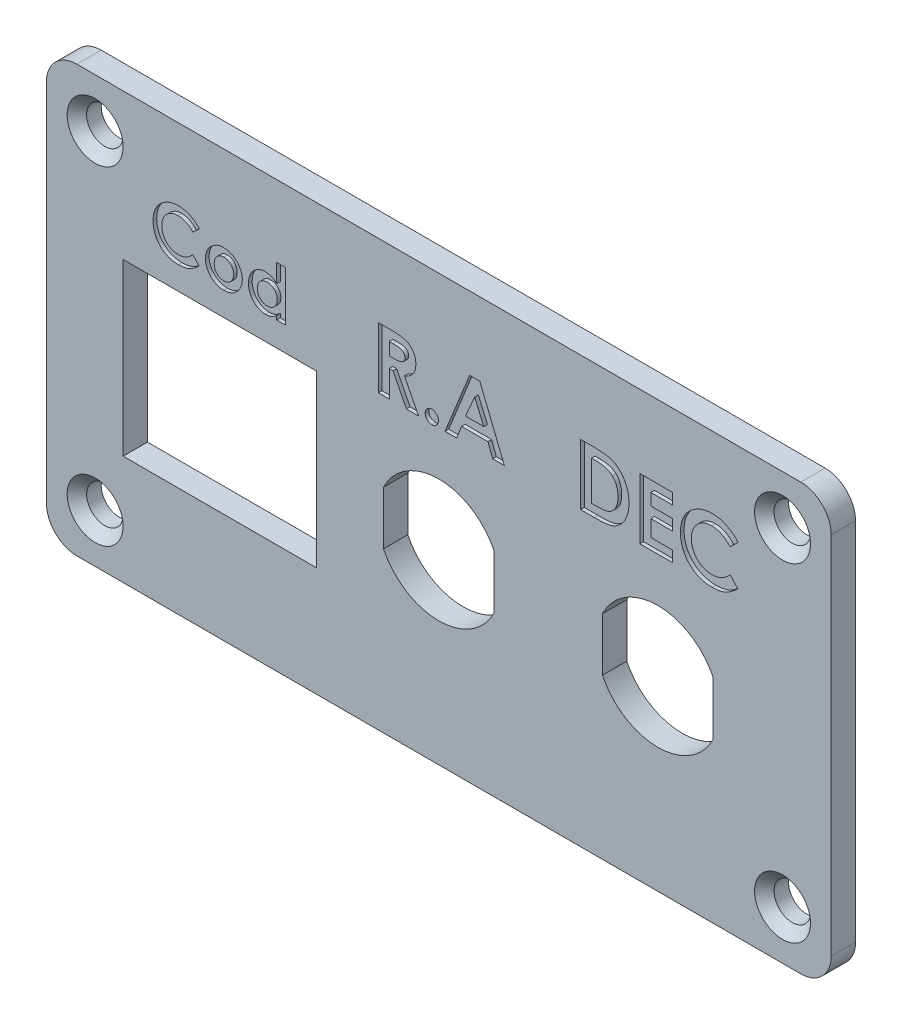
from build123d import *

# Parameters (mm, degrees)
ESQUISSE1_W        = 64.5
ESQUISSE1_H        = 35
ESQUISSE1_R        = 1.5
ESQUISSE1_W_2      = 15.9
ESQUISSE1_H_2      = 14
BOSS_EXTRU_1_DEPTH = 2
CONG_1_R           = 2.5
TEXTE_DEPTH        = 0.3
CHANFREIN1_SIZE    = 0.8


with BuildPart() as part:
    # Esquisse1 → Boss.-Extru.1 (new body)
    with BuildSketch(Plane.XY):
        Rectangle(ESQUISSE1_W, ESQUISSE1_H)
        with Locations((28.25, 13.5)):
            Circle(ESQUISSE1_R, mode=Mode.SUBTRACT)
        with Locations((-28.25, 13.5)):
            Circle(ESQUISSE1_R, mode=Mode.SUBTRACT)
        with Locations((-28.25, -13.5)):
            Circle(ESQUISSE1_R, mode=Mode.SUBTRACT)
        with Locations((28.25, -13.5)):
            Circle(ESQUISSE1_R, mode=Mode.SUBTRACT)
        with BuildLine():
            Line((-4.55, -0.00910977), (-4.55, -4.39089023))
            ThreePointArc((-4.55, -4.39089023), (0, -7.25), (4.55, -4.39089023))
            Line((4.55, -4.39089023), (4.55, -0.00910977))
            ThreePointArc((4.55, -0.00910977), (0, 2.85), (-4.55, -0.00910977))
        make_face(mode=Mode.SUBTRACT)
        with Locations((-18, -1.5)):
            Rectangle(ESQUISSE1_W_2, ESQUISSE1_H_2, mode=Mode.SUBTRACT)
        with BuildLine():
            Line((13.45, -4.39089023), (13.45, -0.00910977))
            ThreePointArc((13.45, -0.00910977), (18, 2.85), (22.55, -0.00910977))
            Line((22.55, -0.00910977), (22.55, -4.39089023))
            ThreePointArc((22.55, -4.39089023), (18, -7.25), (13.45, -4.39089023))
        make_face(mode=Mode.SUBTRACT)
    extrude(amount=BOSS_EXTRU_1_DEPTH)

    # Congé1
    cong_1_edges = [part.edges().sort_by_distance(p)[0] for p in [
        (32.25, -17.5, 1),
        (-32.25, -17.5, 1),
        (-32.25, 17.5, 1),
        (32.25, 17.5, 1),
    ]]
    fillet(cong_1_edges, radius=CONG_1_R)

    # Esquisse2 → Texte (cut)
    with BuildSketch(Plane.XY.offset(2)):
        with BuildLine():
            Line((-4.967948718, 11.5), (-3.922275641, 11.5))
            add(Edge.make_bspline(
                [(-3.922275641, 11.5), (-3.853156969, 11.499754668), (-3.720222293, 11.499282827), (-3.528537751, 11.491838413), (-3.352449138, 11.4814789), (-3.191695739, 11.465670008), (-3.046346327, 11.444709329), (-2.916255229, 11.420000156), (-2.801426245, 11.391838757), (-2.700890954, 11.356747431), (-2.610162824, 11.317164948), (-2.525591594, 11.271683948), (-2.445311496, 11.220810878), (-2.369859116, 11.16320713), (-2.298578754, 11.09990898), (-2.231335937, 11.030852713), (-2.169080867, 10.95545276), (-2.112199031, 10.874185553), (-2.060355816, 10.788694315), (-2.014537288, 10.698861665), (-1.977277584, 10.604625132), (-1.944354642, 10.507346636), (-1.920641313, 10.405635563), (-1.90414904, 10.300482087), (-1.892074042, 10.191516057), (-1.891379788, 10.117489374), (-1.891025641, 10.079727564)],
                knots=[0, 0, 0, 0, 0.000207341, 0.000398776, 0.000575402, 0.000736458, 0.000883205, 0.001015799, 0.001133619, 0.001237515, 0.001334841, 0.001430288, 0.001525314, 0.001619667, 0.00171474, 0.001811071, 0.001908535, 0.00200774, 0.002108399, 0.002208289, 0.002309842, 0.002412147, 0.002516126, 0.002622664, 0.002731397, 0.002844618, 0.002844618, 0.002844618, 0.002844618], degree=3))
            add(Edge.make_bspline(
                [(-1.891025641, 10.079727564), (-1.891945587, 10.040312909), (-1.893749433, 9.963027954), (-1.903465931, 9.849502658), (-1.921224637, 9.740889596), (-1.948122781, 9.637506773), (-1.979038703, 9.53806747), (-2.02014895, 9.444406403), (-2.066545926, 9.355161409), (-2.121650259, 9.271594891), (-2.182124573, 9.19185067), (-2.252454927, 9.118984044), (-2.328084996, 9.049078706), (-2.413266221, 8.98651329), (-2.504243734, 8.92705735), (-2.602825163, 8.873174433), (-2.708367132, 8.823510049), (-2.782568363, 8.795813758), (-2.820512821, 8.781650641)],
                knots=[0, 0, 0, 0, 0.000118257, 0.00023188, 0.000341546, 0.000447947, 0.000552157, 0.000653556, 0.000754365, 0.000853544, 0.000953514, 0.001054124, 0.001156939, 0.001262107, 0.001370733, 0.001482805, 0.001598862, 0.00172032, 0.00172032, 0.00172032, 0.00172032], degree=3))
            Line((-2.820512821, 8.781650641), (-1.666666667, 6.5))
            Line((-1.666666667, 6.5), (-2.664262821, 6.5))
            Line((-2.664262821, 6.5), (-3.766025641, 8.679487179))
            Line((-3.766025641, 8.679487179), (-4.070512821, 8.679487179))
            Line((-4.070512821, 8.679487179), (-4.070512821, 6.5))
            Line((-4.070512821, 6.5), (-4.967948718, 6.5))
            Line((-4.967948718, 6.5), (-4.967948718, 11.5))
        make_face()
        with BuildLine():
            Line((-4.070512821, 9.576923077), (-3.720953526, 9.576923077))
            add(Edge.make_bspline(
                [(-3.720953526, 9.576923077), (-3.678216996, 9.577404404), (-3.596385725, 9.578326043), (-3.478701609, 9.582600986), (-3.371816366, 9.592901485), (-3.275270994, 9.605915781), (-3.188579686, 9.620942666), (-3.112515697, 9.642477103), (-3.045906998, 9.665551798), (-2.989542904, 9.694227658), (-2.941386717, 9.72683833), (-2.899806931, 9.763884865), (-2.865414487, 9.806761511), (-2.837107751, 9.854303067), (-2.815088188, 9.906930027), (-2.799015594, 9.964064664), (-2.790033391, 10.026357817), (-2.788999958, 10.069348574), (-2.788461538, 10.091746795)],
                knots=[0, 0, 0, 0, 0.000128221, 0.000245515, 0.000353154, 0.000450185, 0.000537801, 0.000616775, 0.000687116, 0.000748932, 0.000805883, 0.000861198, 0.000915322, 0.000970118, 0.001026671, 0.001085968, 0.001147728, 0.001214902, 0.001214902, 0.001214902, 0.001214902], degree=3))
            add(Edge.make_bspline(
                [(-2.788461538, 10.091746795), (-2.78947947, 10.118245525), (-2.791479007, 10.17029737), (-2.811320632, 10.245233775), (-2.842904213, 10.314592545), (-2.886196652, 10.3780603), (-2.940717851, 10.433700515), (-3.003285228, 10.482747808), (-3.075249138, 10.521530737), (-3.141882303, 10.547111544), (-3.202502909, 10.562416805), (-3.257211093, 10.57382215), (-3.3205635, 10.581905445), (-3.392607956, 10.590479219), (-3.473160819, 10.596038877), (-3.56266115, 10.600096319), (-3.660851904, 10.601756418), (-3.729300185, 10.602287123), (-3.765024038, 10.602564103)],
                knots=[0, 0, 0, 0, 7.9354e-05, 0.000155877, 0.00023073, 0.000307128, 0.000385047, 0.000463582, 0.000544718, 0.000629358, 0.000676973, 0.000732171, 0.000796904, 0.000868468, 0.00094982, 0.001039053, 0.00113723, 0.001244406, 0.001244406, 0.001244406, 0.001244406], degree=3))
            Line((-3.765024038, 10.602564103), (-4.070512821, 10.602564103))
            Line((-4.070512821, 10.602564103), (-4.070512821, 9.576923077))
        make_face(mode=Mode.SUBTRACT)
        with BuildLine():
            add(Edge.make_bspline(
                [(-0.576923077, 7.525641026), (-0.540694654, 7.523654708), (-0.469367146, 7.519743992), (-0.366308622, 7.490558729), (-0.27329771, 7.438123245), (-0.190133528, 7.369730244), (-0.11981199, 7.287444332), (-0.068985172, 7.19360731), (-0.037334038, 7.090945885), (-0.03383973, 7.019393972), (-0.032051282, 6.982772436)],
                knots=[0, 0, 0, 0, 0.000108636, 0.000213885, 0.000317883, 0.000426763, 0.000535515, 0.000640391, 0.000744962, 0.000854595, 0.000854595, 0.000854595, 0.000854595], degree=3))
            add(Edge.make_bspline(
                [(-0.032051282, 6.982772436), (-0.033828014, 6.946145018), (-0.037299431, 6.874581614), (-0.069204195, 6.771720145), (-0.119736038, 6.677111869), (-0.19013917, 6.59394421), (-0.272953299, 6.524262278), (-0.36652247, 6.472310326), (-0.469170821, 6.441469457), (-0.540660098, 6.437772646), (-0.576923077, 6.435897436)],
                knots=[0, 0, 0, 0, 0.000109633, 0.000214204, 0.000319962, 0.00042948, 0.000538999, 0.000642997, 0.000748527, 0.000857163, 0.000857163, 0.000857163, 0.000857163], degree=3))
            add(Edge.make_bspline(
                [(-0.576923077, 6.435897436), (-0.613194648, 6.437757397), (-0.684700864, 6.441424147), (-0.787508775, 6.472570284), (-0.881768747, 6.523915427), (-0.964603683, 6.594028734), (-1.035321345, 6.676817365), (-1.084416521, 6.772018651), (-1.116618469, 6.874542833), (-1.120042429, 6.946131889), (-1.121794872, 6.982772436)],
                knots=[0, 0, 0, 0, 0.000108636, 0.000214166, 0.000319043, 0.000428562, 0.00053808, 0.000643368, 0.000747938, 0.000857571, 0.000857571, 0.000857571, 0.000857571], degree=3))
            add(Edge.make_bspline(
                [(-1.121794872, 6.982772436), (-1.120030867, 7.019407329), (-1.116584318, 7.09098534), (-1.08463492, 7.193305366), (-1.035242661, 7.287740436), (-0.96460958, 7.369645544), (-0.881422561, 7.438467388), (-0.787723823, 7.490302332), (-0.684504639, 7.519789637), (-0.613160133, 7.523670083), (-0.576923077, 7.525641026)],
                knots=[0, 0, 0, 0, 0.000109633, 0.000214204, 0.000318606, 0.000427357, 0.000536237, 0.000641114, 0.000746364, 0.000854999, 0.000854999, 0.000854999, 0.000854999], degree=3))
        make_face()
        Polygon((2.533052885, 11.5), (3.365384615, 11.5), (5.384615385, 6.5), (4.426081731, 6.5), (4.037459936, 7.525641026), (1.858974359, 7.525641026), (1.470352564, 6.5), (0.512820513, 6.5), align=None)
        Polygon((2.948717949, 10.158854167), (2.199519231, 8.423076923), (3.697916667, 8.423076923), align=None, mode=Mode.SUBTRACT)
        with BuildLine():
            Line((11.653846154, 11.5), (12.784655449, 11.5))
            add(Edge.make_bspline(
                [(12.784655449, 11.5), (12.87281504, 11.499383734), (13.043228526, 11.498192486), (13.290123955, 11.484769979), (13.519705285, 11.464127116), (13.73212051, 11.435729118), (13.926934144, 11.398150789), (14.103894979, 11.351016141), (14.263596938, 11.296607031), (14.40779112, 11.232583672), (14.539426538, 11.157938794), (14.66441857, 11.074790393), (14.782521795, 10.9800925), (14.895393605, 10.875672026), (15.001577366, 10.75961863), (15.102841419, 10.633854577), (15.196706359, 10.496556115), (15.28600952, 10.351015228), (15.366772346, 10.196615127), (15.437216701, 10.034670034), (15.496228364, 9.866222127), (15.544178397, 9.691091883), (15.582400106, 9.509860681), (15.609143066, 9.322162815), (15.625675831, 9.12817206), (15.627352941, 8.996695), (15.628205128, 8.929887821)],
                knots=[0, 0, 0, 0, 0.000264453, 0.000511191, 0.000741521, 0.000955838, 0.001153841, 0.001336301, 0.001504814, 0.001659496, 0.001808829, 0.001958283, 0.002109389, 0.002262474, 0.002419124, 0.002580867, 0.002746456, 0.002917718, 0.003092887, 0.003268727, 0.003447072, 0.00362786, 0.003813103, 0.004002345, 0.004196317, 0.0043967, 0.0043967, 0.0043967, 0.0043967], degree=3))
            add(Edge.make_bspline(
                [(15.628205128, 8.929887821), (15.625973643, 8.835618541), (15.621580833, 8.650043947), (15.584578256, 8.377715368), (15.524732561, 8.116661263), (15.440584078, 7.868923699), (15.336262485, 7.636708815), (15.21163866, 7.424111624), (15.068539879, 7.232273239), (14.908633252, 7.062148859), (14.735493319, 6.915924649), (14.555566015, 6.790694313), (14.36709852, 6.691939744), (14.201032318, 6.629314579), (14.057032202, 6.590367145), (13.930601659, 6.567348836), (13.786989462, 6.546239659), (13.624856552, 6.52992694), (13.444914171, 6.515380005), (13.246445067, 6.507475766), (13.030091826, 6.500908517), (12.879814044, 6.500310774), (12.801682692, 6.5)],
                knots=[0, 0, 0, 0, 0.000282708, 0.000556526, 0.000822811, 0.001085071, 0.001340133, 0.001585264, 0.001822845, 0.002056671, 0.002284055, 0.002501589, 0.002713051, 0.002920663, 0.003032668, 0.003160155, 0.003305912, 0.003468066, 0.003648899, 0.003847421, 0.004063851, 0.004298234, 0.004298234, 0.004298234, 0.004298234], degree=3))
            Line((12.801682692, 6.5), (11.653846154, 6.5))
            Line((11.653846154, 6.5), (11.653846154, 11.5))
        make_face()
        with BuildLine():
            Line((12.551282051, 10.602564103), (12.551282051, 7.397435897))
            Line((12.551282051, 7.397435897), (13.020032051, 7.397435897))
            add(Edge.make_bspline(
                [(13.020032051, 7.397435897), (13.075806102, 7.397538099), (13.18307817, 7.397734665), (13.337954753, 7.407097314), (13.481176323, 7.416494831), (13.612348623, 7.434331632), (13.732426285, 7.454200574), (13.839759756, 7.481850927), (13.936561646, 7.51089528), (14.021649537, 7.547872342), (14.099583113, 7.589492486), (14.171740703, 7.63825531), (14.241392979, 7.692404586), (14.307237737, 7.753532923), (14.369524183, 7.820830867), (14.427883791, 7.894645172), (14.483095507, 7.974750631), (14.533742151, 8.061570781), (14.580023325, 8.15418878), (14.621079913, 8.251707489), (14.655121883, 8.354939029), (14.683415484, 8.462917028), (14.703634471, 8.576581557), (14.720361825, 8.695090719), (14.728985264, 8.818914037), (14.730168777, 8.90316756), (14.730769231, 8.945913462)],
                knots=[0, 0, 0, 0, 0.00016728, 0.000321734, 0.000465387, 0.000597697, 0.000718729, 0.000830231, 0.000930015, 0.001021551, 0.001108043, 0.001194715, 0.001282474, 0.00137249, 0.001463922, 0.001557308, 0.001654546, 0.001755554, 0.001858578, 0.001964979, 0.002072669, 0.002184418, 0.002299537, 0.002418808, 0.002543333, 0.002671573, 0.002671573, 0.002671573, 0.002671573], degree=3))
            add(Edge.make_bspline(
                [(14.730769231, 8.945913462), (14.729573331, 9.011417514), (14.727241419, 9.139145341), (14.704752963, 9.325183709), (14.668146047, 9.500366702), (14.615911504, 9.66404417), (14.550068245, 9.816676131), (14.467650057, 9.95696947), (14.372203902, 10.087280922), (14.296727687, 10.1637258), (14.259014423, 10.201923077)],
                knots=[0, 0, 0, 0, 0.000196439, 0.000383041, 0.000561217, 0.000732585, 0.000897642, 0.001058779, 0.001219838, 0.001380685, 0.001380685, 0.001380685, 0.001380685], degree=3))
            add(Edge.make_bspline(
                [(14.259014423, 10.201923077), (14.221825574, 10.23447232), (14.145871562, 10.300950464), (14.012521275, 10.380608281), (13.865576166, 10.450595482), (13.70167457, 10.506087526), (13.522400524, 10.549973001), (13.326686267, 10.58023974), (13.115579893, 10.599688825), (12.969330316, 10.601585143), (12.893830128, 10.602564103)],
                knots=[0, 0, 0, 0, 0.000147993, 0.00030226, 0.000464002, 0.000635683, 0.000820307, 0.001017083, 0.001229276, 0.001455718, 0.001455718, 0.001455718, 0.001455718], degree=3))
            Line((12.893830128, 10.602564103), (12.551282051, 10.602564103))
        make_face(mode=Mode.SUBTRACT)
        Polygon((16.525641026, 11.5), (19.217948718, 11.5), (19.217948718, 10.602564103), (17.423076923, 10.602564103), (17.423076923, 9.641025641), (19.217948718, 9.641025641), (19.217948718, 8.743589744), (17.423076923, 8.743589744), (17.423076923, 7.397435897), (19.217948718, 7.397435897), (19.217948718, 6.5), (16.525641026, 6.5), align=None)
        with BuildLine():
            Line((24.602564103, 10.632612179), (23.944511218, 10.003605769))
            add(Edge.make_bspline(
                [(23.944511218, 10.003605769), (23.888689811, 10.061325197), (23.779653116, 10.174069323), (23.603953966, 10.32333261), (23.421233247, 10.447723364), (23.235045427, 10.552484465), (23.042041525, 10.631743704), (22.844453193, 10.689501246), (22.641018771, 10.724713837), (22.503342179, 10.72874278), (22.434094551, 10.730769231)],
                knots=[0, 0, 0, 0, 0.000240802, 0.000470361, 0.000690114, 0.000903069, 0.001110094, 0.001314541, 0.001519711, 0.001727335, 0.001727335, 0.001727335, 0.001727335], degree=3))
            add(Edge.make_bspline(
                [(22.434094551, 10.730769231), (22.376264367, 10.729168264), (22.262142869, 10.726008933), (22.094582605, 10.702847918), (21.934302552, 10.663461605), (21.780754048, 10.60917997), (21.634388914, 10.538942415), (21.494900278, 10.452803302), (21.362632044, 10.35154059), (21.239331399, 10.235678217), (21.126540301, 10.109089868), (21.026882185, 9.974020401), (20.943402526, 9.830779254), (20.874892128, 9.680817067), (20.821525177, 9.52343974), (20.783414468, 9.358753228), (20.761372253, 9.1865614), (20.758082305, 9.069506679), (20.756410256, 9.010016026)],
                knots=[0, 0, 0, 0, 0.000173462, 0.000342309, 0.000506284, 0.00066785, 0.000830023, 0.00099236, 0.001158834, 0.001328906, 0.001499173, 0.001666851, 0.001831592, 0.001995638, 0.002160659, 0.002329274, 0.00250196, 0.002680425, 0.002680425, 0.002680425, 0.002680425], degree=3))
            add(Edge.make_bspline(
                [(20.756410256, 9.010016026), (20.756892122, 8.968261323), (20.757841888, 8.885961946), (20.768238761, 8.764218326), (20.784980179, 8.646098234), (20.809209158, 8.531780589), (20.839507735, 8.421166322), (20.875054864, 8.313301171), (20.919648215, 8.209675588), (20.969147507, 8.109086031), (21.026714613, 8.01427721), (21.088782573, 7.923869131), (21.156085142, 7.838304964), (21.229058243, 7.7579345), (21.308728882, 7.684013749), (21.393037866, 7.614319825), (21.483407372, 7.550597403), (21.577960197, 7.491247299), (21.677513157, 7.43968936), (21.77936515, 7.392987827), (21.885060456, 7.355059238), (21.993312173, 7.324485336), (22.103733447, 7.298486798), (22.2174043, 7.2824787), (22.333339349, 7.270355954), (22.411691982, 7.269607445), (22.451121795, 7.269230769)],
                knots=[0, 0, 0, 0, 0.000125236, 0.000246843, 0.000366253, 0.000482938, 0.000597139, 0.000710213, 0.000823319, 0.000935302, 0.001046267, 0.001155731, 0.001264136, 0.00137261, 0.001481028, 0.001589909, 0.001700521, 0.001812531, 0.001924535, 0.002036608, 0.002148451, 0.002260992, 0.002373978, 0.002488433, 0.00260514, 0.002723367, 0.002723367, 0.002723367, 0.002723367], degree=3))
            add(Edge.make_bspline(
                [(22.451121795, 7.269230769), (22.518001533, 7.271165286), (22.649402828, 7.274966109), (22.842253122, 7.304688005), (23.026020239, 7.353578841), (23.172849287, 7.411316078), (23.287885967, 7.46833235), (23.375461691, 7.521069593), (23.466021816, 7.580061989), (23.558062214, 7.647535976), (23.652618159, 7.722681839), (23.748020519, 7.807145412), (23.846711611, 7.898145431), (23.911363168, 7.963093932), (23.944511218, 7.996394231)],
                knots=[0, 0, 0, 0, 0.000200571, 0.000394069, 0.00058382, 0.000770002, 0.000866307, 0.000968686, 0.001076474, 0.001190467, 0.001310914, 0.00143868, 0.001572629, 0.001713571, 0.001713571, 0.001713571, 0.001713571], degree=3))
            Line((23.944511218, 7.996394231), (24.582532051, 7.326322115))
            add(Edge.make_bspline(
                [(24.582532051, 7.326322115), (24.537682621, 7.283021398), (24.450146124, 7.198507659), (24.318099749, 7.078506035), (24.186219559, 6.970671236), (24.057691506, 6.871089331), (23.930410165, 6.782661384), (23.804389035, 6.705299079), (23.68105473, 6.637045812), (23.557846173, 6.579052641), (23.433996698, 6.529810416), (23.306570142, 6.487416092), (23.175176951, 6.45155202), (23.039014634, 6.422614423), (22.899353232, 6.399410377), (22.754885698, 6.383747781), (22.606528029, 6.373218338), (22.505894723, 6.37227218), (22.455128205, 6.371794872)],
                knots=[0, 0, 0, 0, 0.000187024, 0.00036503, 0.000535081, 0.000697952, 0.000852709, 0.000999757, 0.001141405, 0.001275372, 0.001407986, 0.001541014, 0.001678054, 0.001816355, 0.001958459, 0.002102582, 0.002252157, 0.00240443, 0.00240443, 0.00240443, 0.00240443], degree=3))
            add(Edge.make_bspline(
                [(22.455128205, 6.371794872), (22.361876399, 6.374172046), (22.179408537, 6.378823516), (21.912006642, 6.413287757), (21.657982019, 6.471066451), (21.416716675, 6.55278146), (21.188287326, 6.657168554), (20.972752411, 6.78514223), (20.770459325, 6.936362482), (20.583042198, 7.109056861), (20.413514487, 7.299783306), (20.263671623, 7.504571183), (20.1397216, 7.724426951), (20.036803225, 7.956102637), (19.956322409, 8.200655468), (19.899677558, 8.458349975), (19.864745093, 8.728937338), (19.860923431, 8.913754744), (19.858974359, 9.008012821)],
                knots=[0, 0, 0, 0, 0.000279705, 0.000547306, 0.000807285, 0.001060042, 0.001310132, 0.001559378, 0.001810581, 0.002066476, 0.002322583, 0.002575019, 0.002826219, 0.003078225, 0.003334465, 0.003597155, 0.003868729, 0.004151396, 0.004151396, 0.004151396, 0.004151396], degree=3))
            add(Edge.make_bspline(
                [(19.858974359, 9.008012821), (19.859797942, 9.069487134), (19.861430083, 9.191314197), (19.878584037, 9.370775332), (19.902497645, 9.545717838), (19.940434411, 9.714325232), (19.98616344, 9.878868967), (20.043033495, 10.037560644), (20.110953748, 10.190856359), (20.187734969, 10.339012739), (20.274596796, 10.4810592), (20.371630992, 10.615775339), (20.476339519, 10.744201141), (20.591238352, 10.864632798), (20.71465786, 10.978127724), (20.847155269, 11.084070869), (20.987933673, 11.183981576), (21.137374106, 11.27528339), (21.292573339, 11.357870734), (21.451573902, 11.430716299), (21.613985148, 11.491598416), (21.779120388, 11.542097887), (21.947677316, 11.57979217), (22.118452816, 11.608325527), (22.292899982, 11.624275856), (22.410026142, 11.626887027), (22.469150641, 11.628205128)],
                knots=[0, 0, 0, 0, 0.000184363, 0.000365362, 0.000540439, 0.00071372, 0.000883357, 0.001052536, 0.001218914, 0.001386014, 0.001552813, 0.001717916, 0.001883738, 0.002049521, 0.002216815, 0.002386379, 0.002558121, 0.002734369, 0.002911358, 0.003085268, 0.00325865, 0.003431336, 0.003602879, 0.003776434, 0.00395045, 0.004127836, 0.004127836, 0.004127836, 0.004127836], degree=3))
            add(Edge.make_bspline(
                [(22.469150641, 11.628205128), (22.519589901, 11.62744956), (22.619943994, 11.625946278), (22.769388078, 11.613414792), (22.917636979, 11.593734219), (23.064159919, 11.564040426), (23.21000498, 11.528790142), (23.353255596, 11.482634756), (23.496171621, 11.431185881), (23.636511631, 11.369689256), (23.774471519, 11.302560135), (23.906819357, 11.22639971), (24.035777254, 11.145894807), (24.158487581, 11.056280794), (24.277248965, 10.960808139), (24.391440393, 10.859031406), (24.500059768, 10.74925368), (24.568223257, 10.671689237), (24.602564103, 10.632612179)],
                knots=[0, 0, 0, 0, 0.000151295, 0.000301017, 0.000449609, 0.000599682, 0.000749324, 0.000899478, 0.001050942, 0.001204817, 0.001358908, 0.00151097, 0.001662689, 0.001814755, 0.001966487, 0.002119702, 0.002273392, 0.002429436, 0.002429436, 0.002429436, 0.002429436], degree=3))
        make_face()
        with BuildLine():
            Line((-19.692307692, 10.806089744), (-20.21875, 10.302884615))
            add(Edge.make_bspline(
                [(-20.21875, 10.302884615), (-20.263407125, 10.349060158), (-20.350636482, 10.439255459), (-20.491195802, 10.558666088), (-20.637372377, 10.658178691), (-20.786322633, 10.741987572), (-20.940725754, 10.805394963), (-21.09879642, 10.851600997), (-21.261543957, 10.879771069), (-21.371685231, 10.882994224), (-21.427083333, 10.884615385)],
                knots=[0, 0, 0, 0, 0.000192641, 0.000376289, 0.000552091, 0.000722456, 0.000888075, 0.001051633, 0.001215768, 0.001381868, 0.001381868, 0.001381868, 0.001381868], degree=3))
            add(Edge.make_bspline(
                [(-21.427083333, 10.884615385), (-21.473347481, 10.883334611), (-21.564644679, 10.880807146), (-21.698692891, 10.862278335), (-21.826916933, 10.830769284), (-21.949755736, 10.787343976), (-22.066847843, 10.731153932), (-22.178438752, 10.662242641), (-22.284253339, 10.581232472), (-22.382893855, 10.488542574), (-22.473126733, 10.387271894), (-22.552853226, 10.279216321), (-22.619636953, 10.164623403), (-22.674445272, 10.044653653), (-22.717138833, 9.918751792), (-22.7476274, 9.787002582), (-22.765261172, 9.64924912), (-22.76789313, 9.555605343), (-22.769230769, 9.508012821)],
                knots=[0, 0, 0, 0, 0.00013877, 0.000273847, 0.000405028, 0.00053428, 0.000664019, 0.000793888, 0.000927067, 0.001063125, 0.001199338, 0.001333481, 0.001465274, 0.00159651, 0.001728528, 0.001863419, 0.002001568, 0.00214434, 0.00214434, 0.00214434, 0.00214434], degree=3))
            add(Edge.make_bspline(
                [(-22.769230769, 9.508012821), (-22.768845277, 9.474609058), (-22.768085464, 9.408769557), (-22.759767965, 9.311374661), (-22.746374831, 9.216878587), (-22.726991648, 9.125424471), (-22.702752787, 9.036933058), (-22.674315083, 8.950640937), (-22.638640403, 8.867740471), (-22.599040969, 8.787268825), (-22.552987284, 8.711421768), (-22.503332916, 8.639095304), (-22.44949086, 8.570643972), (-22.39111238, 8.5063476), (-22.327375869, 8.447210999), (-22.259928682, 8.39145586), (-22.187633076, 8.340477922), (-22.111990817, 8.29299784), (-22.032348449, 8.251751488), (-21.950866855, 8.214390261), (-21.866310609, 8.184047391), (-21.779709236, 8.159588269), (-21.691372217, 8.138789439), (-21.600435534, 8.12598296), (-21.507687495, 8.116284763), (-21.445005389, 8.115685956), (-21.413461538, 8.115384615)],
                knots=[0, 0, 0, 0, 0.000100189, 0.000197475, 0.000293002, 0.000386351, 0.000477711, 0.000568171, 0.000658655, 0.000748241, 0.000837014, 0.000924585, 0.001011309, 0.001098088, 0.001184823, 0.001271927, 0.001360417, 0.001450024, 0.001539628, 0.001629286, 0.001718761, 0.001808794, 0.001899183, 0.001990746, 0.002084112, 0.002178694, 0.002178694, 0.002178694, 0.002178694], degree=3))
            add(Edge.make_bspline(
                [(-21.413461538, 8.115384615), (-21.359957748, 8.116932229), (-21.254836712, 8.119972887), (-21.100556477, 8.143750404), (-20.953542783, 8.182863073), (-20.836079545, 8.229052863), (-20.744050201, 8.27466588), (-20.673989621, 8.316855674), (-20.601541522, 8.364049591), (-20.527909203, 8.418028781), (-20.452264447, 8.478145471), (-20.375942559, 8.54571633), (-20.296989685, 8.618516345), (-20.24526844, 8.670475145), (-20.21875, 8.697115385)],
                knots=[0, 0, 0, 0, 0.000160457, 0.000315256, 0.000467056, 0.000616001, 0.000693045, 0.000774949, 0.000861179, 0.000952374, 0.001048731, 0.001150944, 0.001258103, 0.001370857, 0.001370857, 0.001370857, 0.001370857], degree=3))
            Line((-20.21875, 8.697115385), (-19.708333333, 8.161057692))
            add(Edge.make_bspline(
                [(-19.708333333, 8.161057692), (-19.744212878, 8.126417119), (-19.814242075, 8.058806127), (-19.919879175, 7.962804828), (-20.025383327, 7.876536989), (-20.12820577, 7.796871465), (-20.230030842, 7.726129107), (-20.330847746, 7.664239263), (-20.429515191, 7.609636649), (-20.528082036, 7.563242113), (-20.627161616, 7.523848333), (-20.729102861, 7.489932874), (-20.834217414, 7.461241616), (-20.943147267, 7.438091539), (-21.054876389, 7.419528302), (-21.170450416, 7.406998225), (-21.289136551, 7.39857467), (-21.369643196, 7.397817744), (-21.41025641, 7.397435897)],
                knots=[0, 0, 0, 0, 0.000149619, 0.000292024, 0.000428065, 0.000558362, 0.000682167, 0.000799805, 0.000913124, 0.001020298, 0.001126388, 0.001232811, 0.001342444, 0.001453084, 0.001566768, 0.001682066, 0.001801725, 0.001923544, 0.001923544, 0.001923544, 0.001923544], degree=3))
            add(Edge.make_bspline(
                [(-21.41025641, 7.397435897), (-21.484857855, 7.399337637), (-21.630832145, 7.403058813), (-21.844753661, 7.430630206), (-22.047973359, 7.47685316), (-22.240985634, 7.542225168), (-22.423729114, 7.625734843), (-22.596157045, 7.728113784), (-22.757991514, 7.849089985), (-22.907925216, 7.987245489), (-23.043547385, 8.139826645), (-23.163421676, 8.303656947), (-23.262581695, 8.479541561), (-23.344916395, 8.66488211), (-23.409301047, 8.860524374), (-23.454616928, 9.06667998), (-23.4825629, 9.28314987), (-23.485620229, 9.431003795), (-23.487179487, 9.506410256)],
                knots=[0, 0, 0, 0, 0.000223764, 0.000437845, 0.000645828, 0.000848034, 0.001048106, 0.001247503, 0.001448465, 0.001653181, 0.001858066, 0.002060015, 0.002260976, 0.00246258, 0.002667572, 0.002877724, 0.003094984, 0.003321117, 0.003321117, 0.003321117, 0.003321117], degree=3))
            add(Edge.make_bspline(
                [(-23.487179487, 9.506410256), (-23.48652062, 9.555589707), (-23.485214908, 9.653051358), (-23.471491745, 9.796620266), (-23.452360858, 9.936574271), (-23.422011446, 10.071460186), (-23.385428223, 10.203095174), (-23.339932178, 10.330048515), (-23.285595976, 10.452685087), (-23.224170999, 10.571210191), (-23.154681538, 10.68484736), (-23.077054181, 10.792620271), (-22.993287359, 10.895360913), (-22.901368293, 10.991706239), (-22.802632686, 11.08250218), (-22.696634759, 11.167256695), (-22.584012036, 11.247185261), (-22.46445969, 11.320226712), (-22.340300303, 11.386296588), (-22.213099853, 11.444573039), (-22.083170856, 11.493278733), (-21.951062664, 11.533678309), (-21.816217121, 11.563833736), (-21.679596721, 11.586660422), (-21.540038989, 11.599420685), (-21.446338061, 11.601509621), (-21.399038462, 11.602564103)],
                knots=[0, 0, 0, 0, 0.00014749, 0.00029229, 0.000432351, 0.000570976, 0.000706686, 0.000842029, 0.000975131, 0.001108811, 0.00124225, 0.001374333, 0.001506991, 0.001639617, 0.001773452, 0.001909103, 0.002046497, 0.002187495, 0.002329087, 0.002468215, 0.00260692, 0.002745068, 0.002882303, 0.003021147, 0.00316036, 0.003302269, 0.003302269, 0.003302269, 0.003302269], degree=3))
            add(Edge.make_bspline(
                [(-21.399038462, 11.602564103), (-21.358687053, 11.601959648), (-21.278403779, 11.600757023), (-21.158848512, 11.590731833), (-21.040249391, 11.574987375), (-20.923031039, 11.551232341), (-20.80635499, 11.523032113), (-20.691754498, 11.486107805), (-20.577421677, 11.444948705), (-20.46514967, 11.395751405), (-20.354781759, 11.342048108), (-20.248903489, 11.281119768), (-20.145737171, 11.216715846), (-20.04756891, 11.145024636), (-19.952559803, 11.068646511), (-19.86120666, 10.987225125), (-19.77431116, 10.899402944), (-19.719780369, 10.837351389), (-19.692307692, 10.806089744)],
                knots=[0, 0, 0, 0, 0.000121036, 0.000240814, 0.000359687, 0.000479746, 0.000599459, 0.000719582, 0.000840753, 0.000963854, 0.001087126, 0.001208776, 0.001330151, 0.001451804, 0.001573189, 0.001695762, 0.001818714, 0.001943549, 0.001943549, 0.001943549, 0.001943549], degree=3))
        make_face()
        with BuildLine():
            add(Edge.make_bspline(
                [(-17.684294872, 10.474358974), (-17.650351642, 10.473754931), (-17.583128668, 10.472558653), (-17.483008445, 10.462600724), (-17.384638554, 10.446353952), (-17.287453579, 10.425317219), (-17.192355973, 10.39584161), (-17.09884696, 10.360490174), (-17.00609045, 10.319902591), (-16.916388642, 10.271589171), (-16.829093508, 10.219188861), (-16.746332526, 10.16138702), (-16.668792968, 10.098637661), (-16.595035436, 10.032395677), (-16.528497151, 9.95977711), (-16.46492596, 9.884281025), (-16.407756458, 9.803202662), (-16.354825734, 9.718517714), (-16.307701891, 9.630715895), (-16.2667835, 9.540407988), (-16.231270184, 9.448842562), (-16.20346397, 9.354904289), (-16.180442987, 9.259831869), (-16.16591511, 9.162460261), (-16.155586797, 9.063789716), (-16.154428666, 8.997356585), (-16.153846154, 8.963942308)],
                knots=[0, 0, 0, 0, 0.000101813, 0.000201636, 0.000301489, 0.000400828, 0.000499682, 0.000599842, 0.000700644, 0.000803162, 0.000905265, 0.001005962, 0.001105698, 0.001204389, 0.001303035, 0.001400909, 0.001500297, 0.001600352, 0.001700371, 0.001798981, 0.001897643, 0.00199473, 0.002092687, 0.00219083, 0.002289855, 0.002390067, 0.002390067, 0.002390067, 0.002390067], degree=3))
            add(Edge.make_bspline(
                [(-16.153846154, 8.963942308), (-16.154460899, 8.930266981), (-16.155683152, 8.863312799), (-16.165541445, 8.763714135), (-16.181850403, 8.665884633), (-16.202967877, 8.569247964), (-16.23233318, 8.475040685), (-16.266643403, 8.381874144), (-16.308760551, 8.291018237), (-16.355324161, 8.20148181), (-16.408595207, 8.115899647), (-16.465715223, 8.034009074), (-16.529020147, 7.957958467), (-16.595025775, 7.885389284), (-16.666862902, 7.818755489), (-16.743384873, 7.756975129), (-16.823929221, 7.69929291), (-16.909075145, 7.647062166), (-16.997732068, 7.601168874), (-17.088404807, 7.559792326), (-17.181623566, 7.525343395), (-17.277195424, 7.497251241), (-17.375178342, 7.475500189), (-17.475355998, 7.46072444), (-17.577512648, 7.450448078), (-17.646341776, 7.449298371), (-17.681089744, 7.448717949)],
                knots=[0, 0, 0, 0, 0.000101012, 0.000200836, 0.000299897, 0.000398455, 0.000497308, 0.000595687, 0.000696087, 0.000797521, 0.000898257, 0.000998298, 0.001096791, 0.001194891, 0.001292404, 0.00139039, 0.001489779, 0.001589412, 0.001689764, 0.001789104, 0.001888233, 0.001987624, 0.002087746, 0.002189057, 0.002291273, 0.002395489, 0.002395489, 0.002395489, 0.002395489], degree=3))
            add(Edge.make_bspline(
                [(-17.681089744, 7.448717949), (-17.731898357, 7.450209282), (-17.832042909, 7.453148722), (-17.979532156, 7.473283117), (-18.121220636, 7.50793969), (-18.257339228, 7.556250189), (-18.388064753, 7.618158294), (-18.512256344, 7.694778974), (-18.631149368, 7.784603788), (-18.742684509, 7.88687353), (-18.844865807, 7.999072697), (-18.934133465, 8.118844625), (-19.009928931, 8.244394133), (-19.072184011, 8.37586439), (-19.120232238, 8.513435677), (-19.154931256, 8.656696704), (-19.175090268, 8.806050157), (-19.178004847, 8.907525202), (-19.179487179, 8.959134615)],
                knots=[0, 0, 0, 0, 0.000152414, 0.000300411, 0.000445585, 0.000589282, 0.000733007, 0.000878677, 0.001026274, 0.001179405, 0.001331996, 0.001480875, 0.001626814, 0.001771263, 0.001916472, 0.002063203, 0.002212787, 0.002367603, 0.002367603, 0.002367603, 0.002367603], degree=3))
            add(Edge.make_bspline(
                [(-19.179487179, 8.959134615), (-19.177953154, 9.014242156), (-19.174938057, 9.122554923), (-19.150996863, 9.281235594), (-19.112765359, 9.433164817), (-19.057886442, 9.577917598), (-18.987783454, 9.715760912), (-18.902203592, 9.846404033), (-18.800723916, 9.969876554), (-18.723010805, 10.044556967), (-18.68349359, 10.082532051)],
                knots=[0, 0, 0, 0, 0.000165258, 0.000324812, 0.000480286, 0.000634465, 0.000788199, 0.000943325, 0.001102143, 0.001266454, 0.001266454, 0.001266454, 0.001266454], degree=3))
            add(Edge.make_bspline(
                [(-18.68349359, 10.082532051), (-18.647232595, 10.114009125), (-18.575697159, 10.176106874), (-18.45947562, 10.254867689), (-18.340477878, 10.322893004), (-18.217277695, 10.378822465), (-18.089531619, 10.420992377), (-17.957894279, 10.451688299), (-17.822393044, 10.470542634), (-17.730561529, 10.473080396), (-17.684294872, 10.474358974)],
                knots=[0, 0, 0, 0, 0.000143939, 0.000283962, 0.000420321, 0.000554807, 0.000689103, 0.000823214, 0.000959879, 0.001098649, 0.001098649, 0.001098649, 0.001098649], degree=3))
        make_face()
        with BuildLine():
            add(Edge.make_bspline(
                [(-17.668269231, 9.807692308), (-17.696066235, 9.806768427), (-17.750784937, 9.804949759), (-17.831332304, 9.795189451), (-17.907514851, 9.775184863), (-17.980845708, 9.749744501), (-18.050027642, 9.715721601), (-18.116955301, 9.675906968), (-18.178148595, 9.626083854), (-18.236568862, 9.571431543), (-18.289601442, 9.510741618), (-18.334790236, 9.444619991), (-18.375167425, 9.375596335), (-18.405783399, 9.30114361), (-18.431121045, 9.223296823), (-18.44826926, 9.140798209), (-18.46020322, 9.05456932), (-18.461089148, 8.995501941), (-18.461538462, 8.965544872)],
                knots=[0, 0, 0, 0, 8.343e-05, 0.000164232, 0.000242745, 0.000319284, 0.000396693, 0.00047365, 0.000552363, 0.000632851, 0.000713507, 0.000793527, 0.000872837, 0.000952905, 0.001034503, 0.001118113, 0.001205375, 0.001295176, 0.001295176, 0.001295176, 0.001295176], degree=3))
            add(Edge.make_bspline(
                [(-18.461538462, 8.965544872), (-18.461012703, 8.934531366), (-18.45998521, 8.873921425), (-18.449345299, 8.78542276), (-18.431799735, 8.701438113), (-18.406872988, 8.622097224), (-18.375523394, 8.546830591), (-18.337061078, 8.476060513), (-18.291080113, 8.410212502), (-18.238948859, 8.349367646), (-18.181867362, 8.294138096), (-18.11932192, 8.246742164), (-18.053931702, 8.205561389), (-17.98418976, 8.17248687), (-17.911086631, 8.146950658), (-17.834405301, 8.128149205), (-17.753742811, 8.118019893), (-17.69874374, 8.11627512), (-17.670673077, 8.115384615)],
                knots=[0, 0, 0, 0, 9.3004e-05, 0.000181758, 0.000266936, 0.000350061, 0.000430867, 0.000511188, 0.000591208, 0.00067134, 0.000751247, 0.000828976, 0.000906352, 0.000982693, 0.001059987, 0.001138308, 0.00121911, 0.00130334, 0.00130334, 0.00130334, 0.00130334], degree=3))
            add(Edge.make_bspline(
                [(-17.670673077, 8.115384615), (-17.642588374, 8.116174453), (-17.587526052, 8.117722993), (-17.506768839, 8.12931911), (-17.429695918, 8.147569113), (-17.355968431, 8.173325106), (-17.286182472, 8.207107567), (-17.220070892, 8.248485357), (-17.157052102, 8.296540524), (-17.099204565, 8.352812151), (-17.045656208, 8.41384676), (-16.998697501, 8.480042378), (-16.959457034, 8.550812474), (-16.927272825, 8.625711763), (-16.902297213, 8.704637295), (-16.88504212, 8.787882427), (-16.873101779, 8.875189177), (-16.872235888, 8.935054342), (-16.871794872, 8.965544872)],
                knots=[0, 0, 0, 0, 8.423e-05, 0.00016514, 0.00024424, 0.000321533, 0.000398943, 0.00047632, 0.000555172, 0.000636212, 0.000717998, 0.000798478, 0.000879185, 0.000960305, 0.001042665, 0.001127059, 0.001215116, 0.001306519, 0.001306519, 0.001306519, 0.001306519], degree=3))
            add(Edge.make_bspline(
                [(-16.871794872, 8.965544872), (-16.872327318, 8.996024745), (-16.873372151, 9.055836145), (-16.88401282, 9.143260975), (-16.901386197, 9.226237036), (-16.926634444, 9.304410026), (-16.9577977, 9.378671775), (-16.996286601, 9.448642165), (-17.04249433, 9.513976574), (-17.094879009, 9.574351038), (-17.152816193, 9.628805591), (-17.214275695, 9.677365834), (-17.280662904, 9.717528885), (-17.350732358, 9.750637576), (-17.424670476, 9.776109988), (-17.502394252, 9.795017995), (-17.584141885, 9.805003171), (-17.639933705, 9.806786561), (-17.668269231, 9.807692308)],
                knots=[0, 0, 0, 0, 9.1402e-05, 0.000179361, 0.000263755, 0.000345352, 0.00042542, 0.000505038, 0.000584401, 0.000665056, 0.000744412, 0.00082263, 0.000899587, 0.000976651, 0.001054701, 0.001133801, 0.001216193, 0.001301224, 0.001301224, 0.001301224, 0.001301224], degree=3))
        make_face(mode=Mode.SUBTRACT)
        with BuildLine():
            Line((-13.333333333, 11.602564103), (-12.615384615, 11.602564103))
            Line((-12.615384615, 11.602564103), (-12.615384615, 7.5))
            Line((-12.615384615, 7.5), (-13.333333333, 7.5))
            Line((-13.333333333, 7.5), (-13.333333333, 7.818910256))
            add(Edge.make_bspline(
                [(-13.333333333, 7.818910256), (-13.368907428, 7.787867873), (-13.43794972, 7.727620736), (-13.546738032, 7.649448544), (-13.655844235, 7.584966589), (-13.765792589, 7.533610228), (-13.878272954, 7.495688841), (-13.994095142, 7.468232872), (-14.114927117, 7.452041415), (-14.197067029, 7.44983731), (-14.238782051, 7.448717949)],
                knots=[0, 0, 0, 0, 0.000141582, 0.000274783, 0.000401213, 0.000521312, 0.000638126, 0.000756683, 0.000877939, 0.001003065, 0.001003065, 0.001003065, 0.001003065], degree=3))
            add(Edge.make_bspline(
                [(-14.238782051, 7.448717949), (-14.285609018, 7.449771409), (-14.378141759, 7.451853106), (-14.513923283, 7.473766329), (-14.645033844, 7.507309399), (-14.771367015, 7.554777037), (-14.892692946, 7.61628579), (-15.009940148, 7.690230809), (-15.121098646, 7.779208006), (-15.227093797, 7.879367564), (-15.324142321, 7.989543791), (-15.408983057, 8.108207455), (-15.480497493, 8.233675575), (-15.539085443, 8.365532166), (-15.585172431, 8.503680452), (-15.618025859, 8.648558599), (-15.63740942, 8.800218348), (-15.639808558, 8.90352303), (-15.641025641, 8.955929487)],
                knots=[0, 0, 0, 0, 0.000140371, 0.000277381, 0.00041148, 0.000545871, 0.000681326, 0.000818925, 0.00096096, 0.001107761, 0.001255954, 0.001400705, 0.001544617, 0.001688458, 0.001832889, 0.001980814, 0.002133472, 0.002290654, 0.002290654, 0.002290654, 0.002290654], degree=3))
            add(Edge.make_bspline(
                [(-15.641025641, 8.955929487), (-15.639748308, 9.010196442), (-15.637242677, 9.116647122), (-15.618914136, 9.272858433), (-15.586666978, 9.421328821), (-15.542695659, 9.562263939), (-15.486134192, 9.695688136), (-15.417246105, 9.821820003), (-15.33509424, 9.940329851), (-15.240428778, 10.04920056), (-15.138213331, 10.148985823), (-15.028860872, 10.235856808), (-14.914081436, 10.309657752), (-14.793753048, 10.369907962), (-14.667892893, 10.416466275), (-14.536997864, 10.450504204), (-14.400486879, 10.470928157), (-14.30749449, 10.473205871), (-14.260416667, 10.474358974)],
                knots=[0, 0, 0, 0, 0.000162787, 0.000319324, 0.000470986, 0.000617973, 0.000761591, 0.000905029, 0.001048396, 0.001193277, 0.001337209, 0.001476365, 0.001611507, 0.001745886, 0.001879246, 0.002013345, 0.002151028, 0.002292199, 0.002292199, 0.002292199, 0.002292199], degree=3))
            add(Edge.make_bspline(
                [(-14.260416667, 10.474358974), (-14.216835462, 10.472976281), (-14.130653628, 10.470242004), (-14.003348214, 10.453030416), (-13.880856228, 10.420622498), (-13.761690009, 10.378867277), (-13.647397159, 10.322678992), (-13.537363633, 10.25518341), (-13.431299512, 10.175523355), (-13.366401557, 10.113921019), (-13.333333333, 10.082532051)],
                knots=[0, 0, 0, 0, 0.000130766, 0.00025859, 0.00038433, 0.000510295, 0.000636798, 0.000765566, 0.000897137, 0.001033828, 0.001033828, 0.001033828, 0.001033828], degree=3))
            Line((-13.333333333, 10.082532051), (-13.333333333, 11.602564103))
        make_face()
        with BuildLine():
            add(Edge.make_bspline(
                [(-14.109775641, 9.807692308), (-14.138383781, 9.806814511), (-14.194453868, 9.805094087), (-14.276912603, 9.794745618), (-14.355718418, 9.776511154), (-14.430309274, 9.74957365), (-14.501796851, 9.716759845), (-14.569095598, 9.675661093), (-14.632760951, 9.627083243), (-14.692418489, 9.572202362), (-14.746805124, 9.51187824), (-14.793689578, 9.446051553), (-14.83353379, 9.376495955), (-14.867231638, 9.303002318), (-14.891351651, 9.224700985), (-14.910454692, 9.142611299), (-14.920367933, 9.056062629), (-14.922164891, 8.997082389), (-14.923076923, 8.967147436)],
                knots=[0, 0, 0, 0, 8.5831e-05, 0.000168223, 0.000248882, 0.000327953, 0.000405744, 0.000484486, 0.000563975, 0.000645635, 0.00072735, 0.000807177, 0.000887581, 0.000967557, 0.001049154, 0.001132937, 0.0012201, 0.001309933, 0.001309933, 0.001309933, 0.001309933], degree=3))
            add(Edge.make_bspline(
                [(-14.923076923, 8.967147436), (-14.922178823, 8.936940955), (-14.920409126, 8.877419435), (-14.910294404, 8.790140696), (-14.89187877, 8.706851872), (-14.865011054, 8.628226297), (-14.83219934, 8.553203051), (-14.792260105, 8.482128373), (-14.743201751, 8.416258953), (-14.68876744, 8.3540361), (-14.627886037, 8.298473506), (-14.563860439, 8.249139025), (-14.495816107, 8.207860895), (-14.424491274, 8.17449965), (-14.350126022, 8.147313039), (-14.271788037, 8.129307745), (-14.190244738, 8.117797302), (-14.134654518, 8.116194398), (-14.106570513, 8.115384615)],
                knots=[0, 0, 0, 0, 9.0633e-05, 0.000178592, 0.000263157, 0.000346015, 0.000427455, 0.000508554, 0.00058997, 0.000673415, 0.000756208, 0.000836819, 0.000915561, 0.000994417, 0.001072734, 0.001152614, 0.001235111, 0.001319341, 0.001319341, 0.001319341, 0.001319341], degree=3))
            add(Edge.make_bspline(
                [(-14.106570513, 8.115384615), (-14.077429513, 8.116267333), (-14.020297311, 8.117997939), (-13.936493303, 8.128251968), (-13.856628844, 8.14655329), (-13.781036212, 8.173645018), (-13.708560803, 8.206223285), (-13.639856642, 8.246518935), (-13.575669271, 8.294985313), (-13.515673613, 8.350362318), (-13.460699158, 8.411179023), (-13.413166329, 8.477868923), (-13.371763496, 8.548299091), (-13.339202073, 8.624134755), (-13.313343736, 8.704049143), (-13.294790976, 8.788538221), (-13.284699351, 8.87769308), (-13.282945132, 8.938544745), (-13.282051282, 8.969551282)],
                knots=[0, 0, 0, 0, 8.7432e-05, 0.000171413, 0.000252853, 0.00033268, 0.000411926, 0.000490945, 0.000571073, 0.000652733, 0.00073558, 0.000816525, 0.000898024, 0.000980197, 0.001063565, 0.001149695, 0.001239245, 0.00133228, 0.00133228, 0.00133228, 0.00133228], degree=3))
            add(Edge.make_bspline(
                [(-13.282051282, 8.969551282), (-13.282934025, 9.000024522), (-13.284658278, 9.059547611), (-13.294834499, 9.146840958), (-13.313518973, 9.229671057), (-13.338845102, 9.30819016), (-13.371985803, 9.382218735), (-13.413419963, 9.45093598), (-13.460431384, 9.516722691), (-13.516014486, 9.5758964), (-13.575685134, 9.630872434), (-13.640816483, 9.677873153), (-13.709356543, 9.718379677), (-13.781726424, 9.751637095), (-13.858596239, 9.776016044), (-13.938597181, 9.794891771), (-14.022977431, 9.805087876), (-14.080370755, 9.806809997), (-14.109775641, 9.807692308)],
                knots=[0, 0, 0, 0, 9.1434e-05, 0.000178597, 0.000263162, 0.000345768, 0.000425744, 0.00050586, 0.000586156, 0.000667816, 0.000748936, 0.000829232, 0.000908251, 0.000987497, 0.001067569, 0.001149789, 0.001233771, 0.001322003, 0.001322003, 0.001322003, 0.001322003], degree=3))
        make_face(mode=Mode.SUBTRACT)
    extrude(amount=-TEXTE_DEPTH, mode=Mode.SUBTRACT)

    # Chanfrein1
    chanfrein1_edges = [part.edges().sort_by_distance(p)[0] for p in [
        (-29.75, -13.5, 2),
        (26.75, 13.5, 2),
        (-29.75, 13.5, 2),
        (26.75, -13.5, 2),
    ]]
    chamfer(chanfrein1_edges, length=CHANFREIN1_SIZE)


solid = part.part
